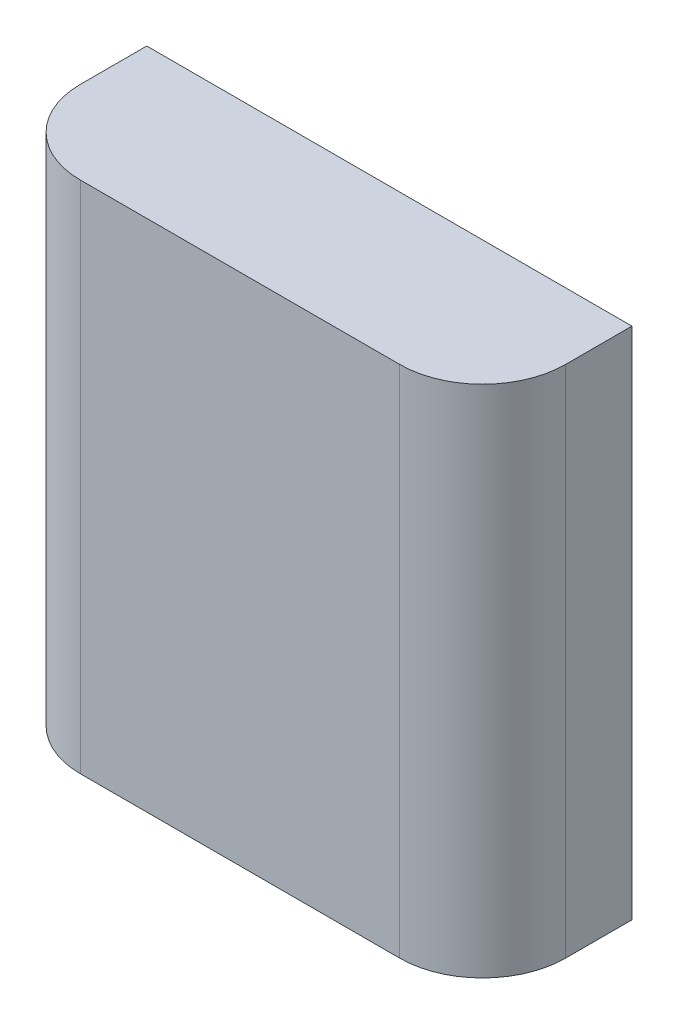
from build123d import *

# Parameters (mm, degrees)
SKETCH1_W           = 58.5
SKETCH1_H           = 62
BOSS_EXTRUDE1_DEPTH = 18
FILLET1_R           = 10


with BuildPart() as part:
    # Sketch1 → Boss-Extrude1 (new body)
    with BuildSketch(Plane.XY):
        Rectangle(SKETCH1_W, SKETCH1_H)
    extrude(amount=BOSS_EXTRUDE1_DEPTH)

    # Fillet1
    fillet1_edges = [part.edges().sort_by_distance(p)[0] for p in [
        (-29.25, 0, 18),
        (29.25, 0, 18),
    ]]
    fillet(fillet1_edges, radius=FILLET1_R)


solid = part.part
